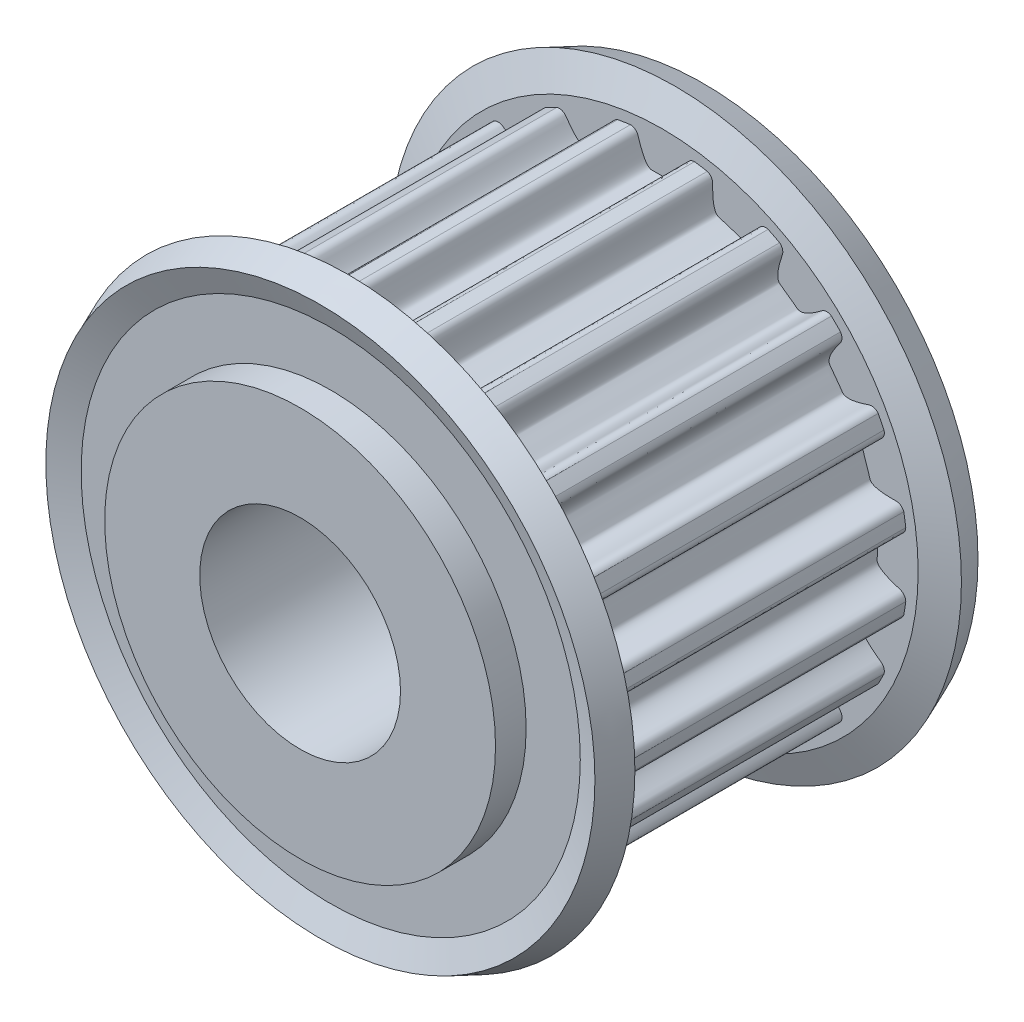
from build123d import *

# Parameters (mm, degrees)
TOOTHEXTRUDECUTGEARBELT01_DEPTH = 3.749999944
PATTERNGEARBELT01_COUNT         = 20
BOREREVOLVESKETCH_W             = 10.547999842
BOREREVOLVESKETCH_H             = 2.5


with BuildPart() as part:
    # SketchRevolveGearBelt01 → GearBelt01 (revolve)
    with BuildSketch(Plane(origin=(0, 0, 0), x_dir=(0, 0, -1), z_dir=(1, 0, 0))):
        Polygon((5.273999921, 0), (5.273999921, 4.866197651), (4.511999932, 4.866197651), (4.511999932, 6.214626406), (4.769626867, 6.836592846), (4.065630673, 7.128197617), (3.749999944, 6.366197628), (3.749999944, 6.110081812), (-3.749999944, 6.110081812), (-3.749999944, 6.366197628), (-4.065630673, 7.128197617), (-4.769626867, 6.836592846), (-4.511999932, 6.214626406), (-4.511999932, 4.866197651), (-5.273999921, 4.866197651), (-5.273999921, 0), align=None)
    revolve(axis=Axis((0, 0, 0), (0, 0, -1)))

    # SketchToothGearBelt01 → ToothExtrudeCutGearBelt01 (cut, symmetric)
    with BuildSketch(Plane.XY):
        with BuildLine():
            ThreePointArc((6.057499697, 0.812101915), (6.1116947, 0), (6.057499697, -0.812101915))
            add(Edge.make_bspline(
                [(6.057499697, -0.812101915), (6.058333892, -0.798636628), (6.05752678, -0.778312876), (6.052390701, -0.751789277), (6.046549263, -0.732387376), (6.038777876, -0.713674757), (6.029156134, -0.695842773), (6.01778237, -0.679074023), (6.004773173, -0.663539298), (5.990260703, -0.649400233), (5.974396793, -0.636791263), (5.957331072, -0.625879395), (5.93928528, -0.616634307), (5.901407836, -0.602783761), (5.851341938, -0.587243165), (5.790886365, -0.567475792), (5.740119979, -0.549822718), (5.692422143, -0.532182602), (5.647797435, -0.514541673), (5.606243662, -0.496903396), (5.56776, -0.479266884), (5.532344907, -0.46163211), (5.499996543, -0.443998471), (5.470712544, -0.426364888), (5.444490091, -0.408729361), (5.421325719, -0.39108843), (5.401216601, -0.373436343), (5.384158786, -0.355764081), (5.370158961, -0.338058507), (5.359207624, -0.320303478), (5.351386789, -0.302483729), (5.346522487, -0.284599108), (5.344349546, -0.250294946), (5.348112416, -0.199977901), (5.348540819, -0.133284358), (5.349542206, -0.066646885), (5.349720908, 0), (5.349542206, 0.066646885), (5.348540819, 0.133284358), (5.348112416, 0.199977901), (5.344349546, 0.250294946), (5.346522487, 0.284599108), (5.351386789, 0.302483729), (5.359207624, 0.320303478), (5.370158961, 0.338058507), (5.384158786, 0.355764081), (5.401216601, 0.373436343), (5.421325719, 0.39108843), (5.444490091, 0.408729361), (5.470712544, 0.426364888), (5.499996543, 0.443998471), (5.532344907, 0.46163211), (5.56776, 0.479266884), (5.606243662, 0.496903396), (5.647797435, 0.514541673), (5.692422143, 0.532182602), (5.740119979, 0.549822718), (5.790886365, 0.567475792), (5.851341938, 0.587243165), (5.901407836, 0.602783761), (5.93928528, 0.616634307), (5.957331072, 0.625879395), (5.974396793, 0.636791263), (5.990260703, 0.649400233), (6.004773173, 0.663539298), (6.01778237, 0.679074023), (6.029156134, 0.695842773), (6.038777876, 0.713674757), (6.046549263, 0.732387376), (6.052390701, 0.751789277), (6.05752678, 0.778312876), (6.058333892, 0.798636628), (6.057499697, 0.812101915)],
                knots=[0, 0, 0, 0, 0.016480534, 0.024720801, 0.032961068, 0.041201335, 0.049441602, 0.057681868, 0.065922135, 0.074162402, 0.082402669, 0.090642936, 0.098883203, 0.10712347, 0.139880128, 0.162959133, 0.184851073, 0.205563721, 0.225106258, 0.243489619, 0.260726943, 0.276834174, 0.291830863, 0.305741243, 0.318595692, 0.33043272, 0.341301658, 0.351266226, 0.36040907, 0.368837047, 0.376686262, 0.384124662, 0.391348897, 0.418550232, 0.445700155, 0.472850077, 0.5, 0.527149923, 0.554299845, 0.581449768, 0.608651103, 0.615875338, 0.623313738, 0.631162953, 0.63959093, 0.648733774, 0.658698342, 0.66956728, 0.681404308, 0.694258757, 0.708169137, 0.723165826, 0.739273057, 0.756510381, 0.774893742, 0.794436279, 0.815148927, 0.837040867, 0.860119872, 0.89287653, 0.901116797, 0.909357064, 0.917597331, 0.925837598, 0.934077865, 0.942318132, 0.950558398, 0.958798665, 0.967038932, 0.975279199, 0.983519466, 1, 1, 1, 1], degree=3))
        make_face()
    toothextrudecutgearbelt01 = extrude(amount=TOOTHEXTRUDECUTGEARBELT01_DEPTH, both=True, mode=Mode.SUBTRACT)

    # PatternGearBelt01: ToothExtrudeCutGearBelt01 ×20 about axis
    patterngearbelt01_axis = Axis((0, 0, 31.132550853), (0, 0, -1))
    for i in range(1, PATTERNGEARBELT01_COUNT):
        add(toothextrudecutgearbelt01.rotate(patterngearbelt01_axis, i * 360 / PATTERNGEARBELT01_COUNT), mode=Mode.SUBTRACT)

    # BoreRevolveSketch → BoreRevolveCut (revolve, cut)
    with BuildSketch(Plane(origin=(0, 0, 0), x_dir=(0, 0, -1), z_dir=(1, 0, 0))):
        with Locations((0, 1.25)):
            Rectangle(BOREREVOLVESKETCH_W, BOREREVOLVESKETCH_H)
    revolve(axis=Axis((0, 0, 0), (0, 0, -1)), mode=Mode.SUBTRACT)


solid = part.part
